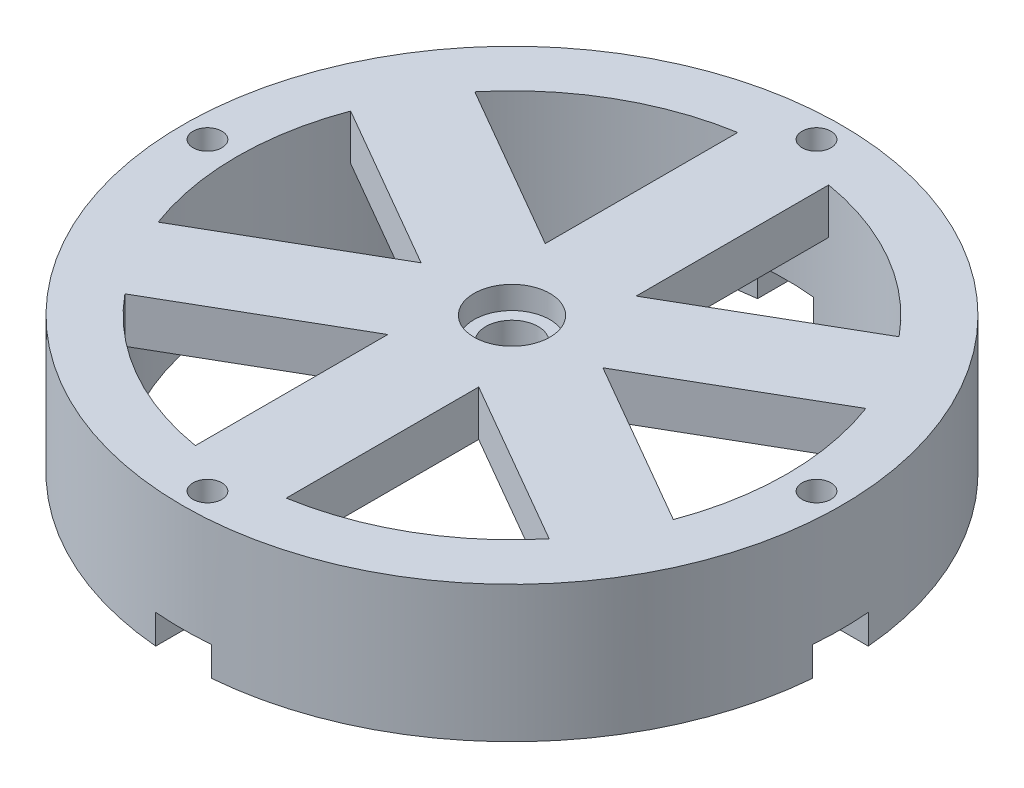
from build123d import *

# Parameters (mm, degrees)
SKETCH1_R               = 72.5
SKETCH1_R_2             = 3.175
BOSS_EXTRUDE1_DEPTH     = 10
SKETCH8_R               = 8.35
CUT_EXTRUDE4_DEPTH      = 5
SKETCH9_R               = 5.75
CUT_EXTRUDE5_DEPTH      = 1
CUT_EXTRUDE5_DEPTH_BACK = 11
SKETCH10_R              = 72.5
SKETCH10_R_2            = 60.5
SKETCH10_R_3            = 3.175
BOSS_EXTRUDE4_DEPTH     = 20
SKETCH11_W              = 32.27284004
SKETCH11_H              = 12.3
SKETCH11_W_2            = 12.3
SKETCH11_H_2            = 32.27284004
CUT_EXTRUDE6_DEPTH      = 6.45
SKETCH12_R              = 2.15
CUT_EXTRUDE7_DEPTH      = 6


with BuildPart() as part:
    # Sketch1 → Boss-Extrude1 (new body)
    with BuildSketch(Plane(origin=(0, 0, 0), x_dir=(1, 0, 0), z_dir=(0, 1, 0))):
        Circle(SKETCH1_R)
        with Locations((0, 67)):
            Circle(SKETCH1_R_2, mode=Mode.SUBTRACT)
        with Locations((67, 0)):
            Circle(SKETCH1_R_2, mode=Mode.SUBTRACT)
        with Locations((0, -67)):
            Circle(SKETCH1_R_2, mode=Mode.SUBTRACT)
        with Locations((-67, 0)):
            Circle(SKETCH1_R_2, mode=Mode.SUBTRACT)
        with BuildLine():
            Line((10, 17.320508076), (10, 59.667830529))
            ThreePointArc((10, 59.667830529), (30.25, 52.394536929), (46.673857027, 38.494169302))
            Line((46.673857027, 38.494169302), (10, 17.320508076))
        make_face(mode=Mode.SUBTRACT)
        with BuildLine():
            Line((-10, 17.320508076), (-10, 59.667830529))
            ThreePointArc((-10, 59.667830529), (-30.25, 52.394536929), (-46.673857027, 38.494169302))
            Line((-46.673857027, 38.494169302), (-10, 17.320508076))
        make_face(mode=Mode.SUBTRACT)
        with BuildLine():
            Line((-20, 0), (-56.673857027, 21.173661227))
            ThreePointArc((-56.673857027, 21.173661227), (-60.5, 0), (-56.673857027, -21.173661226))
            Line((-56.673857027, -21.173661226), (-20, 0))
        make_face(mode=Mode.SUBTRACT)
        with BuildLine():
            Line((-10, -17.320508076), (-46.673857027, -38.494169302))
            ThreePointArc((-46.673857027, -38.494169302), (-30.25, -52.394536929), (-10, -59.667830529))
            Line((-10, -59.667830529), (-10, -17.320508076))
        make_face(mode=Mode.SUBTRACT)
        with BuildLine():
            Line((10, -17.320508076), (10, -59.667830529))
            ThreePointArc((10, -59.667830529), (30.25, -52.394536929), (46.673857027, -38.494169302))
            Line((46.673857027, -38.494169302), (10, -17.320508076))
        make_face(mode=Mode.SUBTRACT)
        with BuildLine():
            Line((20, 0), (56.673857027, 21.173661227))
            ThreePointArc((56.673857027, 21.173661227), (60.5, 0), (56.673857027, -21.173661226))
            Line((56.673857027, -21.173661226), (20, 0))
        make_face(mode=Mode.SUBTRACT)
    extrude(amount=BOSS_EXTRUDE1_DEPTH)

    # Sketch8 → Cut-Extrude4 (cut)
    with BuildSketch(Plane(origin=(0, 10, 0), x_dir=(1, 0, 0), z_dir=(0, 1, 0))):
        Circle(SKETCH8_R)
    extrude(amount=-CUT_EXTRUDE4_DEPTH, mode=Mode.SUBTRACT)

    # Sketch9 → Cut-Extrude5 (cut, two sides)
    with BuildSketch(Plane(origin=(0, 10, 0), x_dir=(1, 0, 0), z_dir=(0, 1, 0))) as cut_extrude5_sk:
        Circle(SKETCH9_R)
    extrude(amount=CUT_EXTRUDE5_DEPTH, mode=Mode.SUBTRACT)
    extrude(cut_extrude5_sk.sketch, amount=-CUT_EXTRUDE5_DEPTH_BACK, mode=Mode.SUBTRACT)

    # Sketch10 → Boss-Extrude4 (add)
    with BuildSketch(Plane.XZ):
        Circle(SKETCH10_R)
        Circle(SKETCH10_R_2, mode=Mode.SUBTRACT)
        with Locations((0, -67)):
            Circle(SKETCH10_R_3, mode=Mode.SUBTRACT)
        with Locations((-67, 0)):
            Circle(SKETCH10_R_3, mode=Mode.SUBTRACT)
        with Locations((0, 67)):
            Circle(SKETCH10_R_3, mode=Mode.SUBTRACT)
        with Locations((67, 0)):
            Circle(SKETCH10_R_3, mode=Mode.SUBTRACT)
    extrude(amount=BOSS_EXTRUDE4_DEPTH)

    # Sketch11 → Cut-Extrude6 (cut)
    with BuildSketch(Plane.XZ.offset(20)):
        with Locations((-60.5, 0)):
            Rectangle(SKETCH11_W, SKETCH11_H)
        with Locations((0, -60.5)):
            Rectangle(SKETCH11_W_2, SKETCH11_H_2)
        with Locations((0, 60.5)):
            Rectangle(SKETCH11_W_2, SKETCH11_H_2)
        with Locations((60.5, 0)):
            Rectangle(SKETCH11_W, SKETCH11_H)
    extrude(amount=-CUT_EXTRUDE6_DEPTH, mode=Mode.SUBTRACT)

    # Sketch12 → Cut-Extrude7 (cut)
    with BuildSketch(Plane.XZ.offset(20)):
        with Locations((33.5, 58.023702054)):
            Circle(SKETCH12_R)
        with Locations((58.023702054, 33.5)):
            Circle(SKETCH12_R)
        with Locations((33.5, -58.023702054)):
            Circle(SKETCH12_R)
        with Locations((58.023702054, -33.5)):
            Circle(SKETCH12_R)
        with Locations((-58.023702054, -33.5)):
            Circle(SKETCH12_R)
        with Locations((-33.5, -58.023702054)):
            Circle(SKETCH12_R)
        with Locations((-33.5, 58.023702054)):
            Circle(SKETCH12_R)
        with Locations((-58.023702054, 33.5)):
            Circle(SKETCH12_R)
    extrude(amount=-CUT_EXTRUDE7_DEPTH, mode=Mode.SUBTRACT)


solid = part.part
